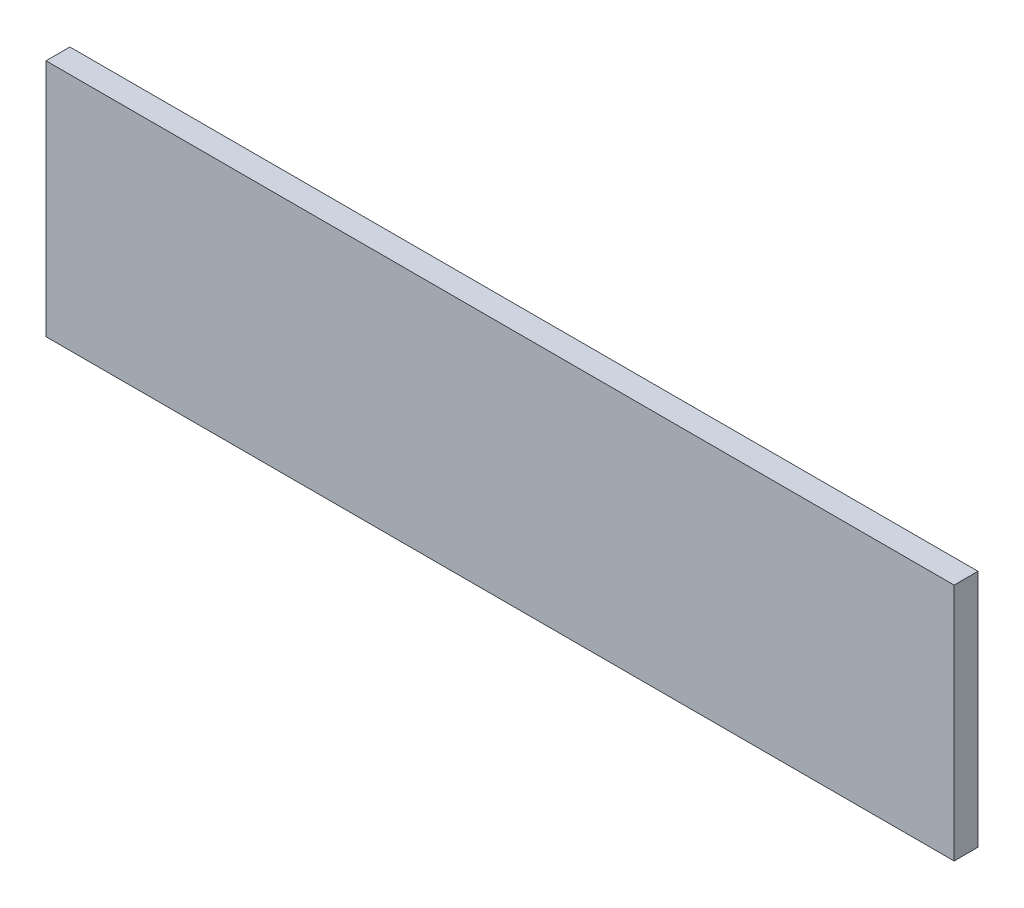
from build123d import *

# Parameters (mm, degrees)
SKETCH1_W           = 482.6
SKETCH1_H           = 127
BOSS_EXTRUDE1_DEPTH = 12.7


with BuildPart() as part:
    # Sketch1 → Boss-Extrude1 (new body)
    with BuildSketch(Plane.XY):
        Rectangle(SKETCH1_W, SKETCH1_H)
    extrude(amount=BOSS_EXTRUDE1_DEPTH)


solid = part.part
